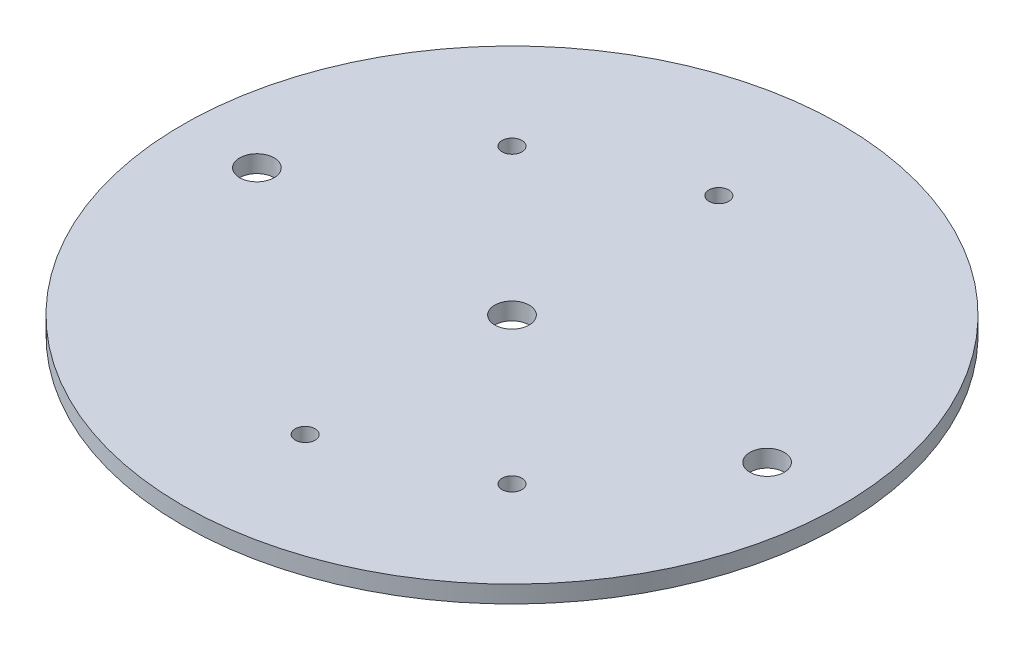
from build123d import *

# Parameters (mm, degrees)
SKETCH2_R           = 60.706
SKETCH2_R_2         = 3.175
SKETCH2_R_3         = 1.8288
BOSS_EXTRUDE1_DEPTH = 3.175


with BuildPart() as part:
    # Sketch2 → Boss-Extrude1 (new body)
    with BuildSketch(Plane(origin=(0, 0, 0), x_dir=(1, 0, 0), z_dir=(0, 1, 0))):
        Circle(SKETCH2_R)
        with Locations((-46.99, 0)):
            Circle(SKETCH2_R_2, mode=Mode.SUBTRACT)
        with Locations((46.99, 0)):
            Circle(SKETCH2_R_2, mode=Mode.SUBTRACT)
        Circle(SKETCH2_R_2, mode=Mode.SUBTRACT)
        with Locations((0, 38.1)):
            Circle(SKETCH2_R_3, mode=Mode.SUBTRACT)
        with Locations((0, -38.1)):
            Circle(SKETCH2_R_3, mode=Mode.SUBTRACT)
        with Locations((-26.940768363, 26.940768363)):
            Circle(SKETCH2_R_3, mode=Mode.SUBTRACT)
        with Locations((26.940768363, -26.940768363)):
            Circle(SKETCH2_R_3, mode=Mode.SUBTRACT)
    extrude(amount=BOSS_EXTRUDE1_DEPTH)


solid = part.part
